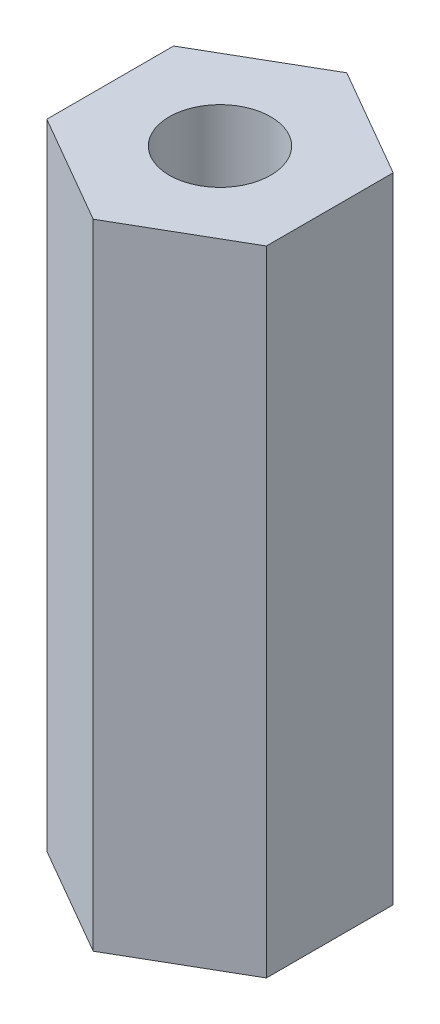
from build123d import *

# Parameters (mm, degrees)
BOSS_EXTRUDE1_DEPTH   = 10
M2X0_4_TAPPED_HOLE1_D = 1.6


with BuildPart() as part:
    # Sketch1 → Boss-Extrude1 (new body)
    with BuildSketch(Plane(origin=(0, 0, 0), x_dir=(1, 0, 0), z_dir=(0, 1, 0))):
        Polygon((1.732050808, -1), (1.732050808, 1), (0, 2), (-1.732050808, 1), (-1.732050808, -1), (0, -2), align=None)
    extrude(amount=BOSS_EXTRUDE1_DEPTH)

    # M2x0.4 Tapped Hole1 (through all)
    with Locations(Plane(origin=(0, 10, 0), x_dir=(1, 0, 0), z_dir=(0, 1, 0))):
        with Locations((0, 0)):
            Hole(M2X0_4_TAPPED_HOLE1_D / 2)


solid = part.part
